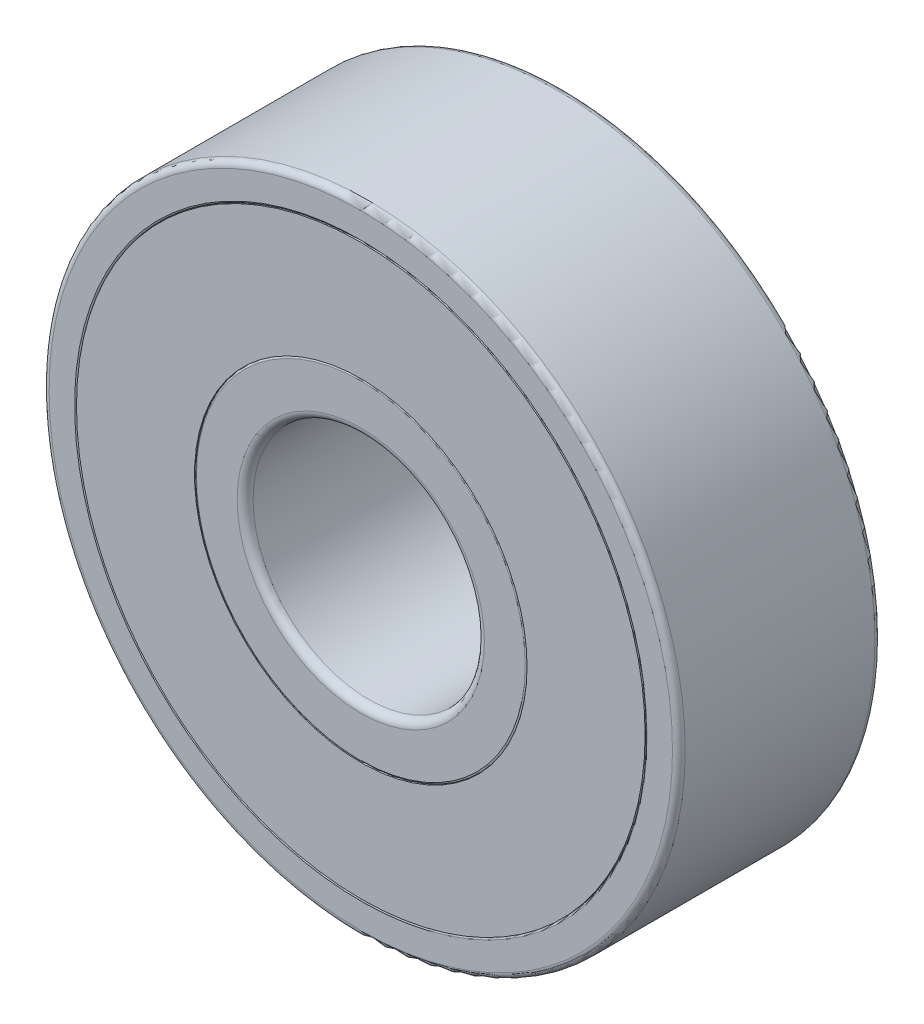
from build123d import *

# Parameters (mm, degrees)
SKETCH3_W           = 7
SKETCH3_H           = 1.166666667
SKETCH3_H_2         = 1.75
SKETCH4_R           = 2.45
CIRPATTERN1_COUNT   = 7
FILLET1_R           = 0.22
FILLET2_R           = 0.275
FILLET3_R           = 0.066
FILLET4_R           = 0.066
SKETCH6_R           = 9.833333333
SKETCH6_R_2         = 5.75
BOSS_EXTRUDE2_DEPTH = 3.5


with BuildPart() as part:
    # Sketch3 → Revolve1 (revolve)
    with BuildSketch(Plane(origin=(0, 0, 0), x_dir=(0, 0, -1), z_dir=(1, 0, 0))):
        with Locations((0, -10.416666666)):
            Rectangle(SKETCH3_W, SKETCH3_H)
        with Locations((0, -4.875)):
            Rectangle(SKETCH3_W, SKETCH3_H_2)
    revolve(axis=Axis((0, 0, 3.5), (0, 0, -1)))

    # Sketch4 → Cut-Revolve1 (revolve, cut)
    with BuildSketch(Plane(origin=(0, 0, 0), x_dir=(0, 0, -1), z_dir=(1, 0, 0))):
        with Locations((0, -7.791666667)):
            Circle(SKETCH4_R)
    revolve(axis=Axis((0, 0, 3.5), (0, 0, -1)), mode=Mode.SUBTRACT)

    # Fillet1
    fillet1_edges = [part.edges().sort_by_distance(p)[0] for p in [
        (0, 11, -3.5),
        (0, 11, 3.5),
    ]]
    fillet(fillet1_edges, radius=FILLET1_R)

    # Fillet2
    fillet2_edges = [part.edges().sort_by_distance(p)[0] for p in [
        (0, 4, -3.5),
        (0, 4, 3.5),
    ]]
    fillet(fillet2_edges, radius=FILLET2_R)

    # Fillet3
    fillet3_edges = [part.edges().sort_by_distance(p)[0] for p in [
        (0, 9.833333333, 3.5),
        (0, 9.833333333, -3.5),
    ]]
    fillet(fillet3_edges, radius=FILLET3_R)

    # Fillet4
    fillet4_edges = [part.edges().sort_by_distance(p)[0] for p in [
        (0, 5.75, 3.5),
        (0, 5.75, -3.5),
    ]]
    fillet(fillet4_edges, radius=FILLET4_R)


with BuildPart() as body_2:
    # Sketch5 → Revolve2 (revolve)
    with BuildSketch(Plane(origin=(0, 0, 0), x_dir=(0, 0, -1), z_dir=(1, 0, 0))):
        with BuildLine():
            Line((0, -5.341666667), (0, -10.241666667))
            ThreePointArc((0, -10.241666667), (2.45, -7.791666667), (0, -5.341666667))
        make_face()
    revolve(axis=Axis((0, -5.341666667, 0), (0, -1, 0)))


with BuildPart() as cirpattern1_1:
    # CirPattern1: pattern copy
    add(body_2.part.rotate(Axis((0, 0, 0), (0, 0, 1)), 1 * 360 / CIRPATTERN1_COUNT))


with BuildPart() as cirpattern1_2:
    # CirPattern1: pattern copy
    add(body_2.part.rotate(Axis((0, 0, 0), (0, 0, 1)), 2 * 360 / CIRPATTERN1_COUNT))


with BuildPart() as cirpattern1_3:
    # CirPattern1: pattern copy
    add(body_2.part.rotate(Axis((0, 0, 0), (0, 0, 1)), 3 * 360 / CIRPATTERN1_COUNT))


with BuildPart() as cirpattern1_4:
    # CirPattern1: pattern copy
    add(body_2.part.rotate(Axis((0, 0, 0), (0, 0, 1)), 4 * 360 / CIRPATTERN1_COUNT))


with BuildPart() as cirpattern1_5:
    # CirPattern1: pattern copy
    add(body_2.part.rotate(Axis((0, 0, 0), (0, 0, 1)), 5 * 360 / CIRPATTERN1_COUNT))


with BuildPart() as cirpattern1_6:
    # CirPattern1: pattern copy
    add(body_2.part.rotate(Axis((0, 0, 0), (0, 0, 1)), 6 * 360 / CIRPATTERN1_COUNT))


with BuildPart() as body_9:
    # Sketch6 → Boss-Extrude2 (new body, symmetric)
    with BuildSketch(Plane.XY):
        Circle(SKETCH6_R)
        Circle(SKETCH6_R_2, mode=Mode.SUBTRACT)
    extrude(amount=BOSS_EXTRUDE2_DEPTH, both=True)


solid = Compound([part.part, body_2.part, cirpattern1_1.part, cirpattern1_2.part, cirpattern1_3.part, cirpattern1_4.part, cirpattern1_5.part, cirpattern1_6.part, body_9.part])
